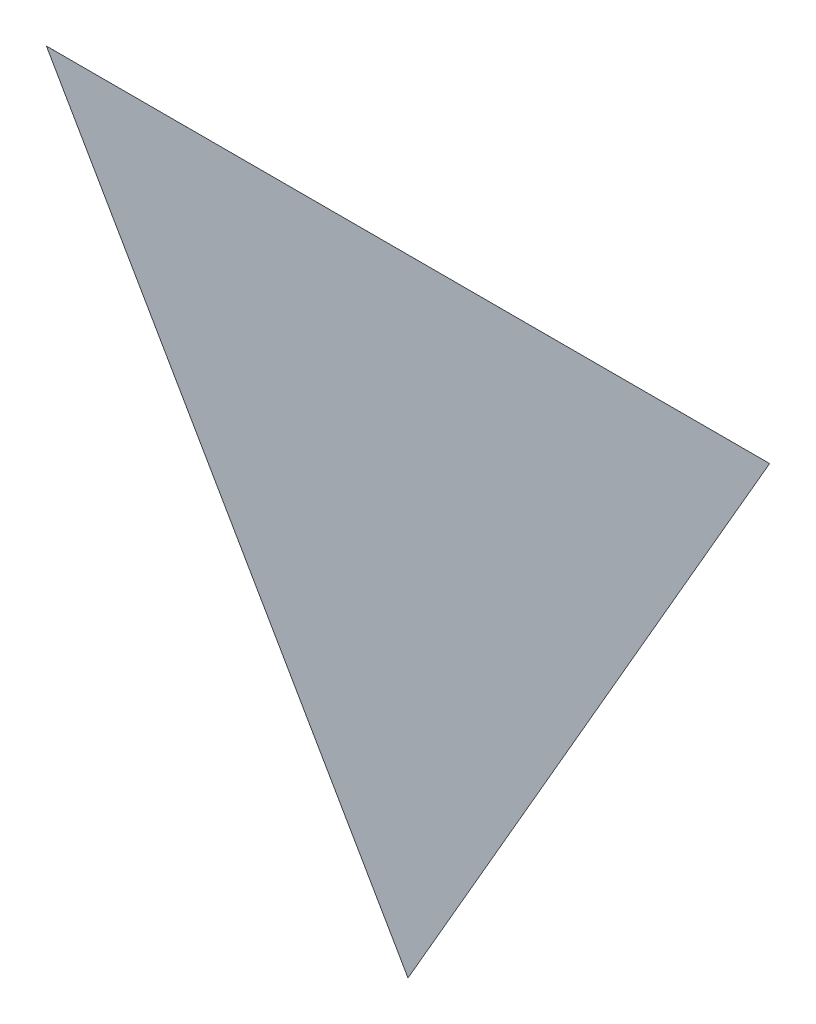
from build123d import *

# Parameters (mm, degrees)
SALIENTE_EXTRUIR1_DEPTH = 0.0001


with BuildPart() as part:
    # Croquis1 → Saliente-Extruir1 (new body)
    with BuildSketch(Plane.XY):
        Polygon((-60.698645159, 26.002554745), (-35.698645159, 26.002554745), (-48.198645159, 4.35191965), align=None)
    extrude(amount=SALIENTE_EXTRUIR1_DEPTH)


solid = part.part
